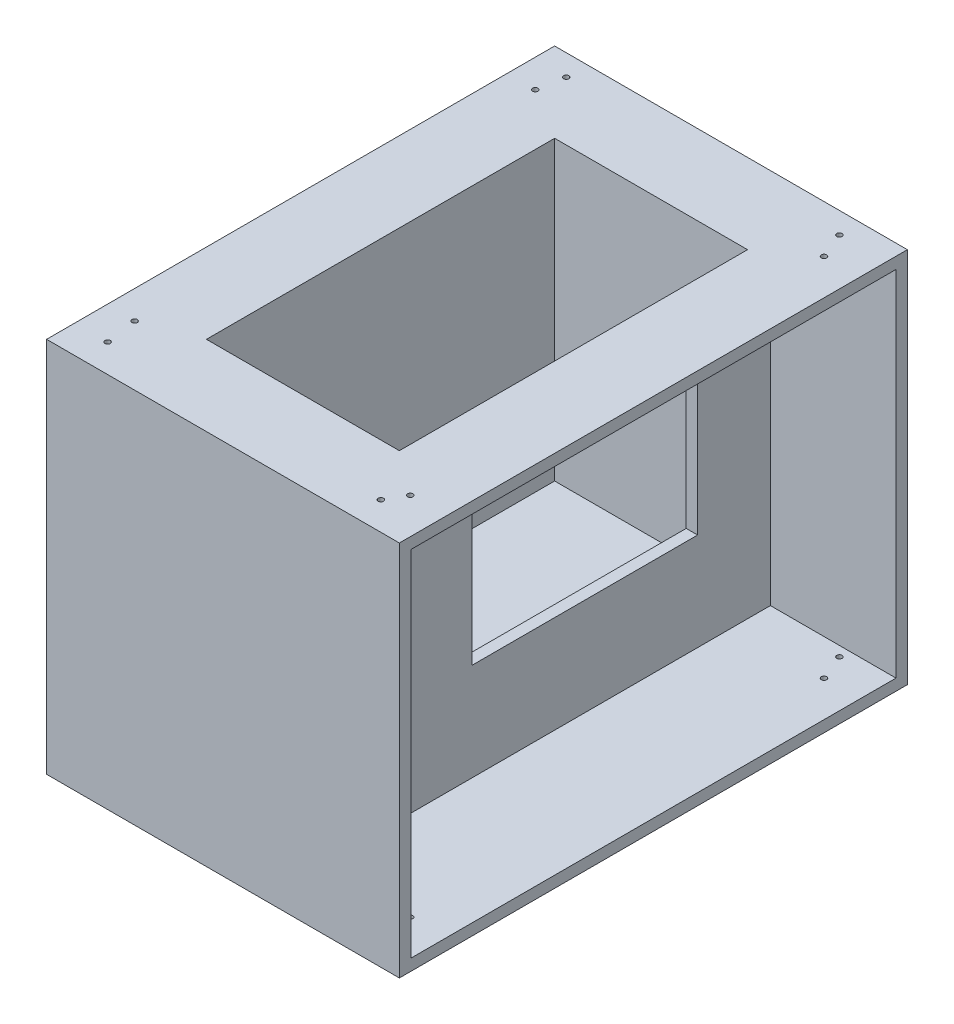
from build123d import *

# Parameters (mm, degrees)
SKETCH1_W                = 78.486
SKETCH1_H                = 113.03
BOSS_EXTRUDE1_DEPTH      = 68.326
BOSS_EXTRUDE1_DEPTH_BACK = 15.494
SHELL1_T                 = -17.78
SHELL5_T                 = -2.54
SKETCH2_W                = 50.166140906
SKETCH2_H                = 33.974952571
CUT_EXTRUDE1_DEPTH       = 12.446
F_0_80_TAPPED_HOLE1_D    = 1.19126


with BuildPart() as part:
    # Sketch1 → Boss-Extrude1 (new body, two sides)
    with BuildSketch(Plane(origin=(0, 0, 0), x_dir=(1, 0, 0), z_dir=(0, 1, 0))) as boss_extrude1_sk:
        Rectangle(SKETCH1_W, SKETCH1_H)
    extrude(amount=BOSS_EXTRUDE1_DEPTH)
    extrude(boss_extrude1_sk.sketch, amount=-BOSS_EXTRUDE1_DEPTH_BACK)

    # Shell1
    shell1_openings = [part.faces().sort_by_distance(p)[0] for p in [
        (0, 68.326, 0),
    ]]
    offset(amount=SHELL1_T, openings=shell1_openings, kind=Kind.INTERSECTION)

    # Shell5
    shell5_openings = [part.faces().sort_by_distance(p)[0] for p in [
        (39.243, 26.416, 0),
    ]]
    offset(amount=SHELL5_T, openings=shell5_openings, kind=Kind.INTERSECTION)

    # Sketch2 → Cut-Extrude1 (cut)
    with BuildSketch(Plane(origin=(24.003, 0, 0), x_dir=(0, 0, -1), z_dir=(1, 0, 0))):
        with Locations((0, 38.426676593)):
            Rectangle(SKETCH2_W, SKETCH2_H)
    extrude(amount=-CUT_EXTRUDE1_DEPTH, mode=Mode.SUBTRACT)

    # #0-80 Tapped Hole1 (through all)
    with Locations(Plane(origin=(0, 68.326, 0), x_dir=(1, 0, 0), z_dir=(0, 1, 0))):
        with Locations((-31.94519897, 51.782137041), (-32.97568926, 45.942692068), (28.853728102, 51.782137041), (31.258205444, 45.942692068), (31.258205444, -46.114440449), (28.853728102, -50.236401607), (-31.94519897, -50.236401607), (-32.97568926, -43.194717963)):
            Hole(F_0_80_TAPPED_HOLE1_D / 2)


solid = part.part
